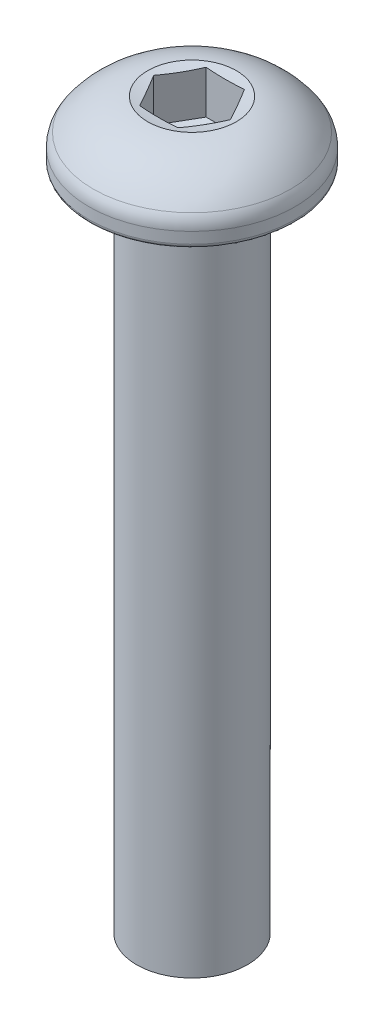
from build123d import *

# Parameters (mm, degrees)
FILLET1_R           = 0.2
FILLET2_R           = 1
SKETCH2_R           = 2.5
BOSS_EXTRUDE1_DEPTH = 30
CUT_EXTRUDE1_DEPTH  = 2


with BuildPart() as part:
    # Sketch1 → Revolve1 (revolve)
    with BuildSketch(Plane.XY):
        with BuildLine():
            Line((0, 0), (4.65, 0))
            Line((4.65, 0), (4.65, 1))
            ThreePointArc((4.65, 1), (3.526943142, 2.164793721), (2, 2.7))
            Line((2, 2.7), (0, 2.7))
            Line((0, 2.7), (0, 0))
        make_face()
    revolve(axis=Axis((0, 55, 0), (0, -1, 0)))

    # Fillet1
    fillet1_edges = [part.edges().sort_by_distance(p)[0] for p in [
        (-4.65, 0, 0),
    ]]
    fillet(fillet1_edges, radius=FILLET1_R)

    # Fillet2
    fillet2_edges = [part.edges().sort_by_distance(p)[0] for p in [
        (-4.65, 1, 0),
    ]]
    fillet(fillet2_edges, radius=FILLET2_R)

    # Sketch2 → Boss-Extrude1 (add)
    with BuildSketch(Plane.XZ):
        Circle(SKETCH2_R)
    extrude(amount=BOSS_EXTRUDE1_DEPTH)

    # Sketch6 → Revolve2 (revolve)
    with BuildSketch(Plane.XY):
        Polygon((0, 0), (0, 2.7), (1.274203424, 2.7), (4.45, 0), align=None)
    revolve(axis=Axis((0, 55, 0), (0, -1, 0)))

    # Sketch7 → Cut-Extrude1 (cut)
    with BuildSketch(Plane(origin=(0, 2.7, 0), x_dir=(1, 0, 0), z_dir=(0, 1, 0))):
        Polygon((0.866025404, -1.5), (1.732050808, 0), (0.866025404, 1.5), (-0.866025404, 1.5), (-1.732050808, 0), (-0.866025404, -1.5), align=None)
    extrude(amount=-CUT_EXTRUDE1_DEPTH, mode=Mode.SUBTRACT)

    # Sketch8 → Cut-Revolve1 (revolve, cut)
    with BuildSketch(Plane.XY):
        with BuildLine():
            Line((0, 0.7), (0, 0.2))
            ThreePointArc((0, 0.2), (0.877315732, 0.410889157), (1.732050808, 0.7))
            Line((1.732050808, 0.7), (0, 0.7))
        make_face()
    revolve(axis=Axis((0, 55, 0), (0, -1, 0)), mode=Mode.SUBTRACT)

    # Sketch9 → Cut-Revolve2 (revolve, cut)
    with BuildSketch(Plane.XY):
        with BuildLine():
            ThreePointArc((0, 2.497958971), (1.00508962, 2.548597441), (2, 2.7))
            Line((2, 2.7), (0, 2.7))
            Line((0, 2.7), (0, 2.497958971))
        make_face()
    revolve(axis=Axis((0, 55, 0), (0, -1, 0)), mode=Mode.SUBTRACT)


solid = part.part
